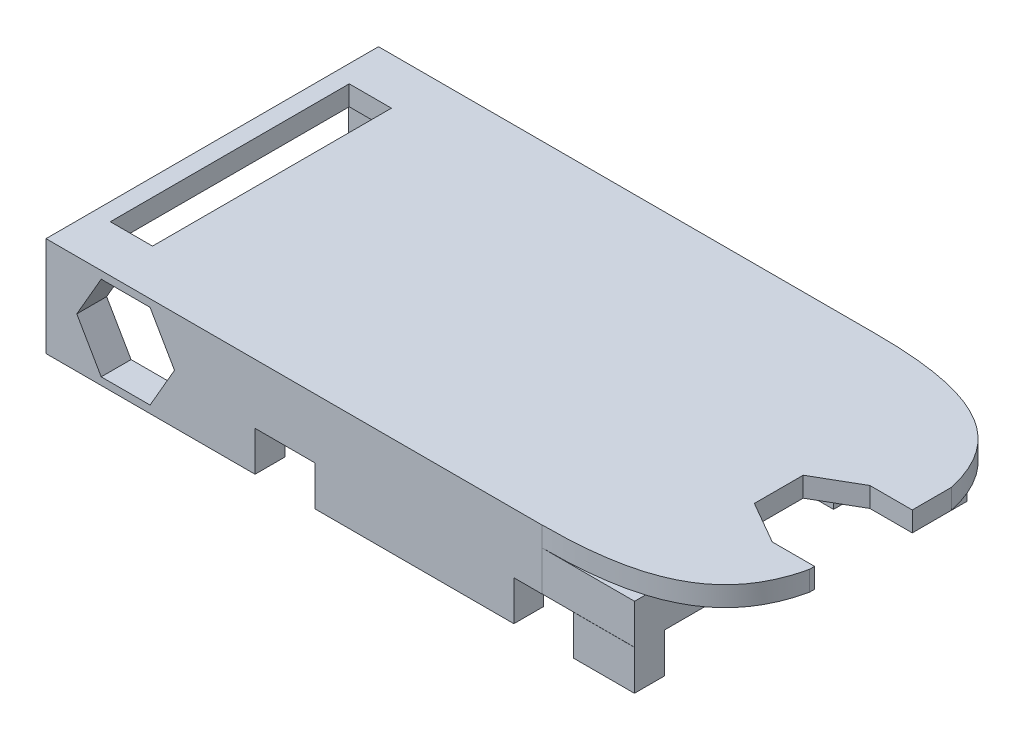
from build123d import *

# Parameters (mm, degrees)
SKETCH1_W              = 22.5552
SKETCH1_H              = 12.7
BOSS_EXTRUDE1_DEPTH    = 1
SKETCH2_W              = 5
SKETCH2_H              = 7.3
CUT_EXTRUDE1_DEPTH     = 1
SKETCH3_W              = 5
SKETCH3_H              = 5
CUT_EXTRUDE2_DEPTH     = 1
BOSS_EXTRUDE2_DEPTH    = 1
SKETCH5_W              = 33.5552
SKETCH5_H              = 16.7
BOSS_EXTRUDE3_DEPTH    = 1
CUT_EXTRUDE4_DEPTH     = 1
CUT_EXTRUDE5_START     = -4
CUT_EXTRUDE5_DEPTH     = 5
SKETCH10_W             = 22.5552
SKETCH10_H             = 2
BOSS_EXTRUDE4_DEPTH    = 2
SKETCH11_W             = 8.919893548
SKETCH11_H             = 0.730490532
CUT_EXTRUDE6_DEPTH     = 3
SKETCH12_W             = 22.5552
SKETCH12_H             = 1.5
BOSS_EXTRUDE5_DEPTH    = 2
SKETCH13_W             = 3
SKETCH13_H             = 1.5
CUT_EXTRUDE7_DEPTH     = 2
SKETCH14_W             = 2.125
SKETCH14_H             = 1.226869322
CUT_EXTRUDE8_DEPTH     = 1
SKETCH15_W             = 2.12
SKETCH15_H             = 12
ADAPTER_PCB_HOLE_DEPTH = 1
SKETCH16_W             = 7
SKETCH16_H             = 1.5
BOSS_EXTRUDE6_DEPTH    = 4
NUT_HOLE_DEPTH         = 1.5
SKETCH20_W             = 7
SKETCH20_H             = 1.5
BOSS_EXTRUDE7_DEPTH    = 4
NUT_HOLE2_DEPTH        = 1.5


with BuildPart() as part:
    # Sketch1 → Boss-Extrude1 (new body)
    with BuildSketch(Plane(origin=(0, 0, 0), x_dir=(1, 0, 0), z_dir=(0, 1, 0))):
        with Locations((-28.763088774, 14.606547542)):
            Rectangle(SKETCH1_W, SKETCH1_H)
    extrude(amount=BOSS_EXTRUDE1_DEPTH)

    # Sketch2 → Cut-Extrude1 (cut)
    with BuildSketch(Plane(origin=(0, 1, 0), x_dir=(1, 0, 0), z_dir=(0, 1, 0))):
        with Locations((-37.540688774, 14.606547542)):
            Rectangle(SKETCH2_W, SKETCH2_H)
    extrude(amount=-CUT_EXTRUDE1_DEPTH, mode=Mode.SUBTRACT)

    # Sketch3 → Cut-Extrude2 (cut)
    with BuildSketch(Plane(origin=(0, 1, 0), x_dir=(1, 0, 0), z_dir=(0, 1, 0))):
        with Locations((-19.985488774, 13.756547542)):
            Rectangle(SKETCH3_W, SKETCH3_H)
    extrude(amount=-CUT_EXTRUDE2_DEPTH, mode=Mode.SUBTRACT)

    # Sketch4 → Boss-Extrude2 (add)
    with BuildSketch(Plane.XZ):
        Polygon((-40.040688774, -8.256547542), (-40.040688774, -8.756547542), (-17.985488774, -8.756547542), (-17.985488774, -10.256547542), (-17.485488774, -10.256547542), (-17.485488774, -8.256547542), align=None)
        Polygon((-17.985488774, -20.456547542), (-40.040688774, -20.456547542), (-40.040688774, -20.956547542), (-17.485488774, -20.956547542), (-17.485488774, -18.456547542), (-17.985488774, -18.456547542), align=None)
    extrude(amount=BOSS_EXTRUDE2_DEPTH)

    # Sketch5 → Boss-Extrude3 (add)
    with BuildSketch(Plane(origin=(0, 1, 0), x_dir=(1, 0, 0), z_dir=(0, 1, 0))):
        with Locations((-30.263088774, 14.606547542)):
            Rectangle(SKETCH5_W, SKETCH5_H)
    extrude(amount=BOSS_EXTRUDE3_DEPTH)

    # Sketch7 → Cut-Extrude4 (cut)
    with BuildSketch(Plane(origin=(0, 1, 0), x_dir=(-1, 0, 0), z_dir=(0, -1, 0))):
        Polygon((17.735488774, 14.983416864), (15.610488774, 16.210286186), (13.485488774, 14.983416864), (13.485488774, 12.52967822), (15.610488774, 11.302808898), (17.735488774, 12.52967822), align=None)
    extrude(amount=-CUT_EXTRUDE4_DEPTH, mode=Mode.SUBTRACT)

    # Sketch8 → Cut-Extrude5 (cut)
    with BuildSketch(Plane(origin=(0, 2, 0), x_dir=(1, 0, 0), z_dir=(0, 1, 0)).offset(CUT_EXTRUDE5_START)):
        with BuildLine():
            Line((-13.485488774, 22.956547542), (-22.127760886, 22.956547542))
            add(Edge.make_bspline(
                [(-22.127760886, 22.956547542), (-17.367981555, 22.956547542), (-14.30272025, 21.87197064), (-13.485488774, 18.176213027)],
                knots=[0, 0, 0, 0, 1, 1, 1, 1], degree=3))
            Line((-13.485488774, 18.176213027), (-13.485488774, 22.956547542))
        make_face()
    cut_extrude5 = extrude(amount=CUT_EXTRUDE5_DEPTH, mode=Mode.SUBTRACT)

    # Mirror2: Cut-Extrude5 across plane
    add(cut_extrude5.mirror(Plane.XY.offset(-14.61)), mode=Mode.SUBTRACT)

    # Sketch10 → Boss-Extrude4 (add)
    with BuildSketch(Plane(origin=(0, 1, 0), x_dir=(-1, 0, 0), z_dir=(0, -1, 0))):
        with Locations((28.763088774, 7.256547542)):
            Rectangle(SKETCH10_W, SKETCH10_H)
        with Locations((28.763088774, 21.956547542)):
            Rectangle(SKETCH10_W, SKETCH10_H)
    extrude(amount=BOSS_EXTRUDE4_DEPTH)

    # Sketch11 → Cut-Extrude6 (cut)
    with BuildSketch(Plane(origin=(0, 2, 0), x_dir=(1, 0, 0), z_dir=(0, 1, 0))):
        with Locations((-17.667814112, 5.898207192)):
            Rectangle(SKETCH11_W, SKETCH11_H)
    extrude(amount=-CUT_EXTRUDE6_DEPTH, mode=Mode.SUBTRACT)

    # Sketch12 → Boss-Extrude5 (add)
    with BuildSketch(Plane(origin=(0, -1, 0), x_dir=(-1, 0, 0), z_dir=(0, -1, 0))):
        with Locations((28.763088774, 7.006547542)):
            Rectangle(SKETCH12_W, SKETCH12_H)
        with Locations((28.763088774, 22.206547542)):
            Rectangle(SKETCH12_W, SKETCH12_H)
    extrude(amount=BOSS_EXTRUDE5_DEPTH)

    # Sketch13 → Cut-Extrude7 (cut)
    with BuildSketch(Plane(origin=(0, -3, 0), x_dir=(-1, 0, 0), z_dir=(0, -1, 0))):
        with Locations((35.040688774, 7.006547542)):
            Rectangle(SKETCH13_W, SKETCH13_H)
        with Locations((35.040688774, 22.206547542)):
            Rectangle(SKETCH13_W, SKETCH13_H)
        with Locations((22.040688774, 7.006547542)):
            Rectangle(SKETCH13_W, SKETCH13_H)
        with Locations((22.040688774, 22.206547542)):
            Rectangle(SKETCH13_W, SKETCH13_H)
    extrude(amount=-CUT_EXTRUDE7_DEPTH, mode=Mode.SUBTRACT)

    # Sketch14 → Cut-Extrude8 (cut)
    with BuildSketch(Plane(origin=(0, 2, 0), x_dir=(1, 0, 0), z_dir=(0, 1, 0))):
        with Locations((-14.547988774, 15.596851525)):
            Rectangle(SKETCH14_W, SKETCH14_H)
        with Locations((-14.547988774, 11.916243559)):
            Rectangle(SKETCH14_W, SKETCH14_H)
    extrude(amount=-CUT_EXTRUDE8_DEPTH, mode=Mode.SUBTRACT)

    # Sketch15 → adapter_PCB_hole (cut)
    with BuildSketch(Plane(origin=(0, 1, 0), x_dir=(-1, 0, 0), z_dir=(0, -1, 0))):
        with Locations((45.100688774, 14.606547542)):
            Rectangle(SKETCH15_W, SKETCH15_H)
    extrude(amount=-ADAPTER_PCB_HOLE_DEPTH, mode=Mode.SUBTRACT)

    # Sketch16 → Boss-Extrude6 (add)
    with BuildSketch(Plane(origin=(0, 1, 0), x_dir=(-1, 0, 0), z_dir=(0, -1, 0))):
        with Locations((43.540688774, 22.206547542)):
            Rectangle(SKETCH16_W, SKETCH16_H)
    extrude(amount=BOSS_EXTRUDE6_DEPTH)

    # Sketch19 → nut_hole (cut)
    with BuildSketch(Plane(origin=(0, 0, -22.956547542), x_dir=(-1, 0, 0), z_dir=(0, 0, -1))):
        Polygon((45.494427418, -0.5), (44.267558096, 1.625), (41.813819452, 1.625), (40.58695013, -0.5), (41.813819452, -2.625), (44.267558096, -2.625), align=None)
    extrude(amount=-NUT_HOLE_DEPTH, mode=Mode.SUBTRACT)

    # Sketch20 → Boss-Extrude7 (add)
    with BuildSketch(Plane(origin=(0, 1, 0), x_dir=(-1, 0, 0), z_dir=(0, -1, 0))):
        with Locations((43.540688774, 7.006547542)):
            Rectangle(SKETCH20_W, SKETCH20_H)
    extrude(amount=BOSS_EXTRUDE7_DEPTH)

    # Sketch21 → nut_hole2 (cut)
    with BuildSketch(Plane.XY.offset(-6.256547542)):
        Polygon((-45.494427418, -0.5), (-44.267558096, -2.625), (-41.813819452, -2.625), (-40.58695013, -0.5), (-41.813819452, 1.625), (-44.267558096, 1.625), align=None)
    extrude(amount=-NUT_HOLE2_DEPTH, mode=Mode.SUBTRACT)


solid = part.part
